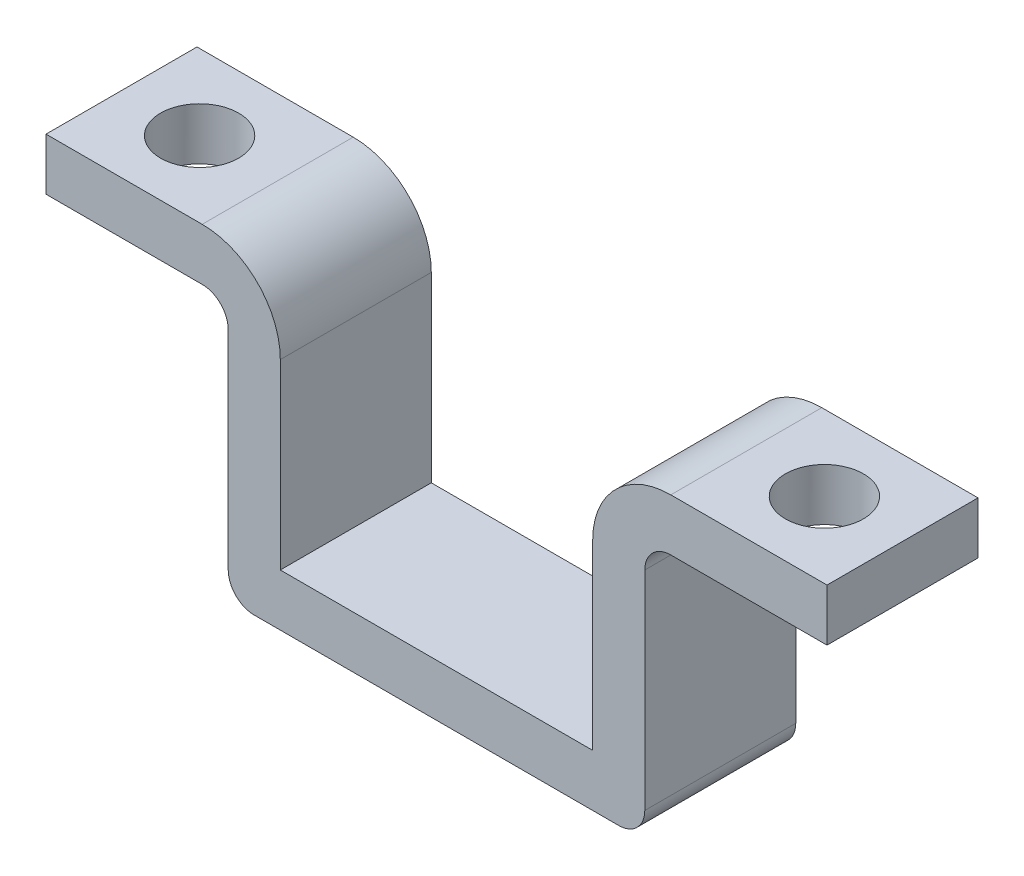
from build123d import *

# Parameters (mm, degrees)
BOSS_EXTRUDE1_DEPTH = 2.9
SKETCH5_R           = 1.5
CUT_EXTRUDE1_DEPTH  = 13


with BuildPart() as part:
    # Sketch3 → Boss-Extrude1 (new body, symmetric)
    with BuildSketch(Plane.XY):
        with BuildLine():
            Line((-6, -5), (6, -5))
            Line((6, -5), (6, 2))
            ThreePointArc((6, 2), (6.878679656, 4.121320344), (9, 5))
            Line((9, 5), (15, 5))
            Line((15, 5), (15, 3))
            Line((15, 3), (9, 3))
            ThreePointArc((9, 3), (8.292893219, 2.707106781), (8, 2))
            Line((8, 2), (8, -6))
            ThreePointArc((8, -6), (7.707106781, -6.707106781), (7, -7))
            Line((7, -7), (-7, -7))
            ThreePointArc((-7, -7), (-7.707106781, -6.707106781), (-8, -6))
            Line((-8, -6), (-8, 2))
            ThreePointArc((-8, 2), (-8.292893219, 2.707106781), (-9, 3))
            Line((-9, 3), (-15, 3))
            Line((-15, 3), (-15, 5))
            Line((-15, 5), (-9, 5))
            ThreePointArc((-9, 5), (-6.878679656, 4.121320344), (-6, 2))
            Line((-6, 2), (-6, -5))
        make_face()
    extrude(amount=BOSS_EXTRUDE1_DEPTH, both=True)

    # Sketch5 → Cut-Extrude1 (cut, through all)
    with BuildSketch(Plane(origin=(0, 5, 0), x_dir=(1, 0, 0), z_dir=(0, 1, 0))):
        with Locations((12, 0)):
            Circle(SKETCH5_R)
        with Locations((-12, 0)):
            Circle(SKETCH5_R)
    extrude(amount=-CUT_EXTRUDE1_DEPTH, mode=Mode.SUBTRACT)


solid = part.part
